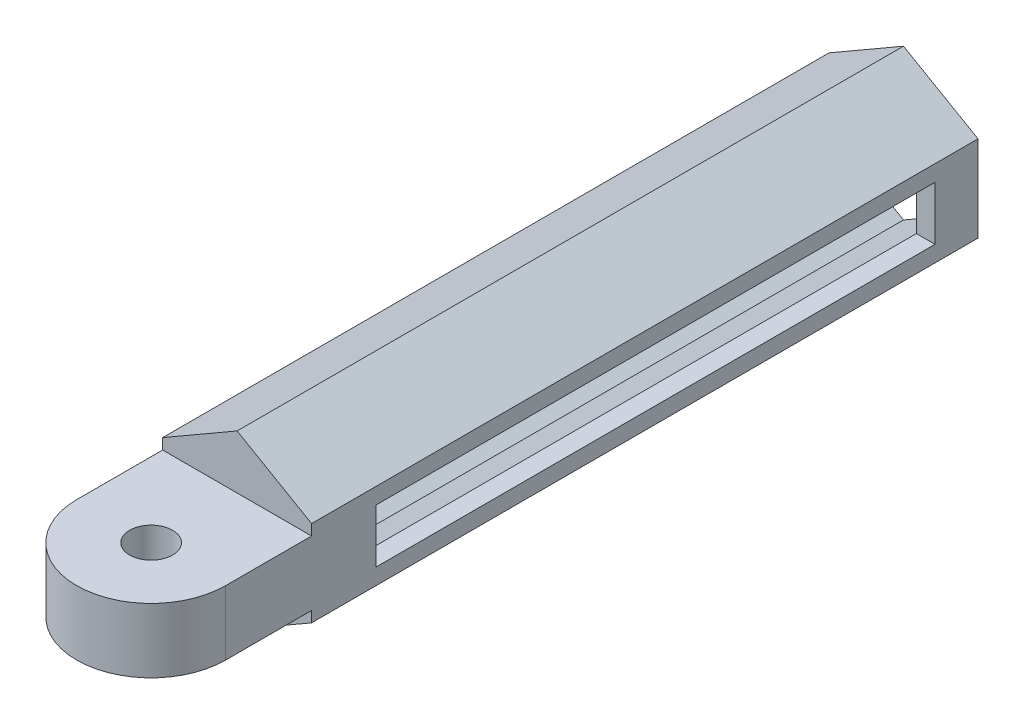
from build123d import *

# Parameters (mm, degrees)
EXTRUDE_1_DEPTH      = 30
EXTRUDE_2_DEPTH      = 1
SKETCH_3_W           = 26
SKETCH_3_H           = 2.5
CUT_EXTRUDE_1_DEPTH  = 6.928203
SKETCH_7_R           = 1
EXTRUDE_3_DEPTH      = 1.5
EXTRUDE_3_DEPTH_BACK = 1.5


with BuildPart() as part:
    # 스케치1 → 보스-돌출1 (new body)
    with BuildSketch(Plane.XY):
        Polygon((0, 4), (-3.464101615, 2), (-3.464101615, -2), (0, -4), (3.464101615, -2), (3.464101615, 2), align=None)
        Polygon((0, 3), (-2.598076211, 1.5), (-2.598076211, -1.5), (0, -3), (2.598076211, -1.5), (2.598076211, 1.5), align=None, mode=Mode.SUBTRACT)
    extrude(amount=EXTRUDE_1_DEPTH)

    # 스케치4 → 보스-돌출2 (add)
    with BuildSketch(Plane.XY.offset(30)):
        Polygon((0, 4), (-3.464101615, 2), (-3.464101615, -2), (0, -4), (3.464101615, -2), (3.464101615, 2), align=None)
    extrude(amount=EXTRUDE_2_DEPTH)

    # 스케치3 → 컷-돌출1 (cut)
    with BuildSketch(Plane(origin=(3.464101615, 0, 0), x_dir=(0, 0, -1), z_dir=(1, 0, 0))):
        with Locations((-15, 0)):
            Rectangle(SKETCH_3_W, SKETCH_3_H)
    extrude(amount=-CUT_EXTRUDE_1_DEPTH, mode=Mode.SUBTRACT)

    # 스케치7 → 보스-돌출3 (add, two sides)
    with BuildSketch(Plane(origin=(0, 0, 0), x_dir=(1, 0, 0), z_dir=(0, 1, 0))) as extrude_3_sk:
        with BuildLine():
            Line((3.464101615, -31), (-3.464101615, -31))
            Line((-3.464101615, -31), (-3.464101615, -35))
            ThreePointArc((-3.464101615, -35), (0, -38.464101615), (3.464101615, -35))
            Line((3.464101615, -35), (3.464101615, -31))
        make_face()
        with Locations((0, -35)):
            Circle(SKETCH_7_R, mode=Mode.SUBTRACT)
    extrude(amount=EXTRUDE_3_DEPTH)
    extrude(extrude_3_sk.sketch, amount=-EXTRUDE_3_DEPTH_BACK)


solid = part.part
